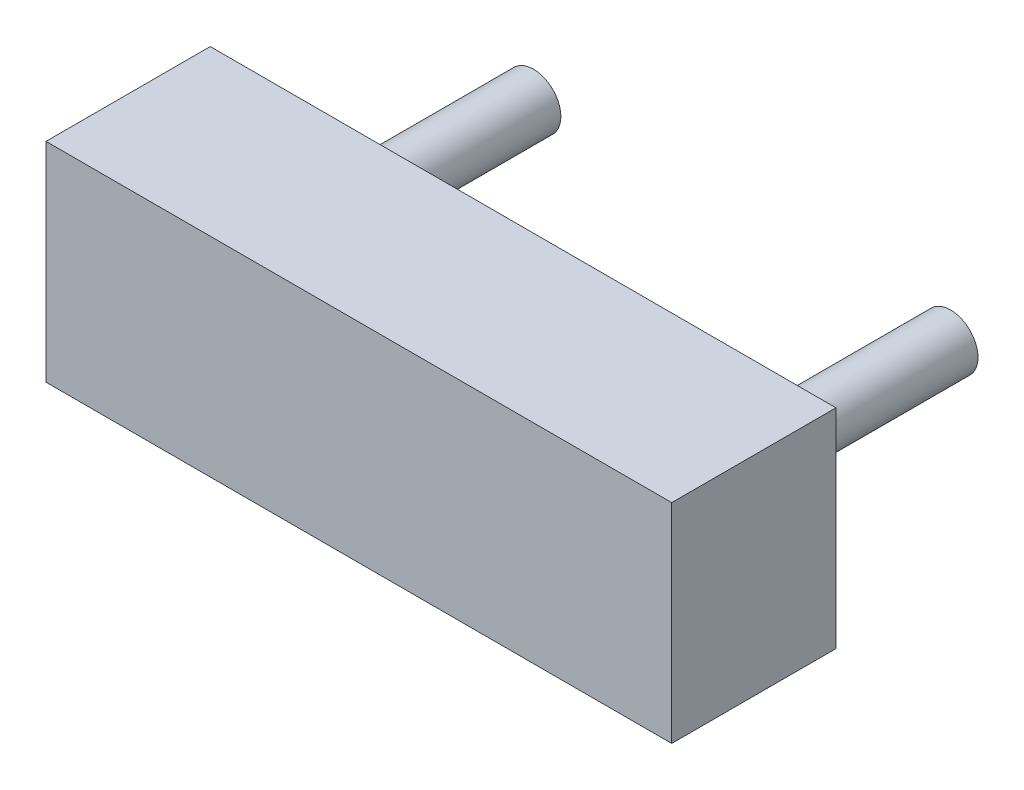
from build123d import *

# Parameters (mm, degrees)
SKETCH1_W               = 5.715
SKETCH1_H               = 1.905
COMPONENT_OUTLINE_DEPTH = 1.5
SKETCH2_R               = 0.25
EXTRUDE_1_DEPTH         = 2
SKETCH3_R               = 0.25
EXTRUDE_2_DEPTH         = 2


with BuildPart() as part:
    # Sketch1 → Component_Outline (new body)
    with BuildSketch(Plane.XY):
        Rectangle(SKETCH1_W, SKETCH1_H)
    extrude(amount=COMPONENT_OUTLINE_DEPTH)


with BuildPart() as body_2:
    # Sketch2 → Extrude 1 (new body)
    with BuildSketch(Plane.XY):
        with Locations((-1.905, 0)):
            Circle(SKETCH2_R)
    extrude(amount=-EXTRUDE_1_DEPTH)


with BuildPart() as body_3:
    # Sketch3 → Extrude 2 (new body)
    with BuildSketch(Plane.XY):
        with Locations((1.905, 0)):
            Circle(SKETCH3_R)
    extrude(amount=-EXTRUDE_2_DEPTH)


solid = Compound([part.part, body_2.part, body_3.part])
